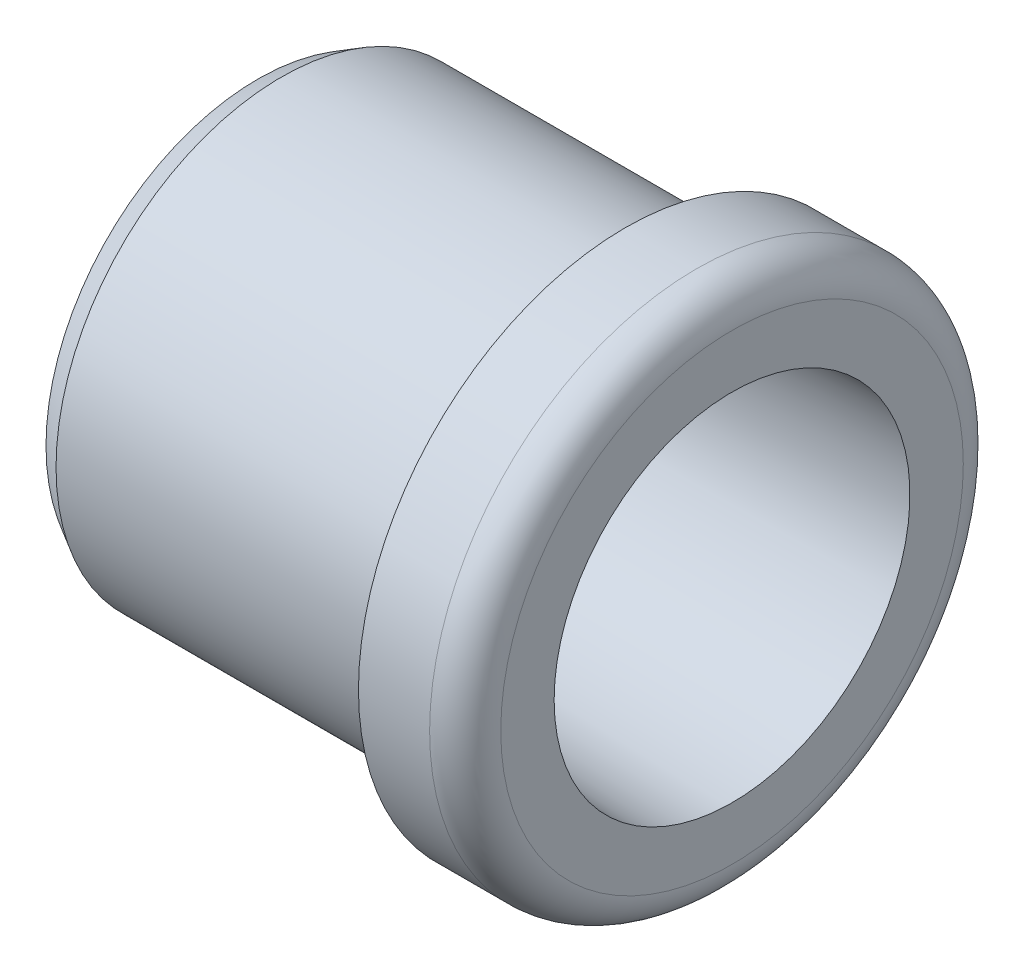
from build123d import *


with BuildPart() as part:
    # Sketch1 → Revolve1 (revolve)
    with BuildSketch(Plane.XY):
        with BuildLine():
            Line((0, 17.845299462), (2, 19))
            Line((2, 19), (31, 19))
            Line((31, 19), (31, 22.5))
            Line((31, 22.5), (37, 22.5))
            ThreePointArc((37, 22.5), (39.121320344, 21.621320344), (40, 19.5))
            Line((40, 19.5), (40, 15))
            Line((40, 15), (12.772080403, 14.049180096))
            ThreePointArc((12.772080403, 14.049180096), (12.22452816, 13.805394131), (12, 13.249667434))
            Line((12, 13.249667434), (12, 5.1))
            Line((12, 5.1), (0, 5.1))
            Line((0, 5.1), (0, 17.845299462))
        make_face()
    revolve(axis=Axis((0, 0, 0), (1, 0, 0)))


solid = part.part
